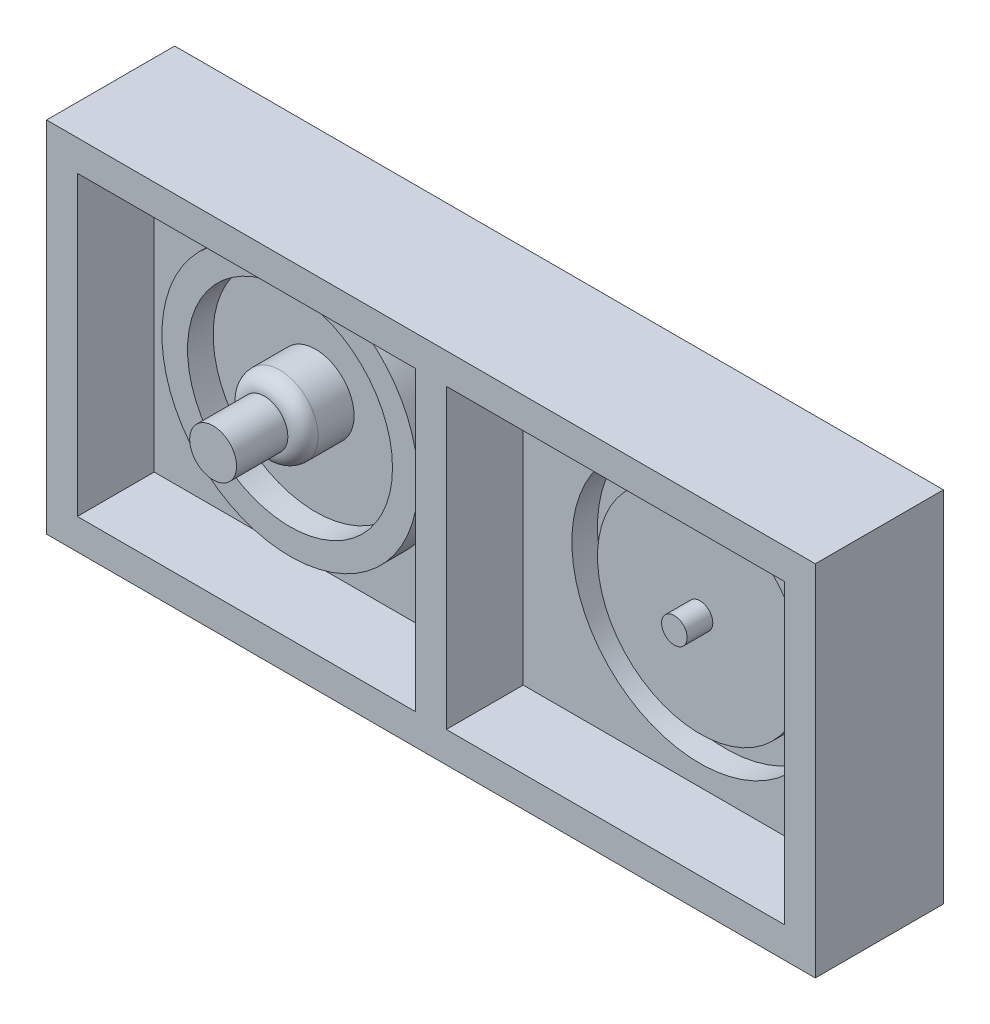
from build123d import *

# Parameters (mm, degrees)
ESQUISSE1_W             = 150
ESQUISSE1_H             = 70
BOSS_EXTRU_1_DEPTH      = 25
ESQUISSE2_W             = 66
ESQUISSE2_H             = 58
ENL_V_MAT_EXTRU_1_DEPTH = 15
ESQUISSE3_R             = 25
ESQUISSE3_R_2           = 20
BOSS_EXTRU_2_DEPTH      = 5
ESQUISSE4_R             = 25
ESQUISSE4_R_2           = 20
ENL_V_MAT_EXTRU_2_DEPTH = 5
ESQUISSE5_R             = 7.5
BOSS_EXTRU_3_DEPTH      = 10
CONG_2_R                = 3
ESQUISSE6_R             = 2.5
BOSS_EXTRU_4_DEPTH      = 5
ESQUISSE7_R             = 4.575268676
BOSS_EXTRU_5_DEPTH      = 10


with BuildPart() as part:
    # Esquisse1 → Boss.-Extru.1 (new body)
    with BuildSketch(Plane.XY):
        with Locations((75, 35)):
            Rectangle(ESQUISSE1_W, ESQUISSE1_H)
    extrude(amount=BOSS_EXTRU_1_DEPTH)

    # Esquisse2 → Enlèv. mat.-Extru.1 (cut)
    with BuildSketch(Plane.XY.offset(25)):
        with Locations((39, 35)):
            Rectangle(ESQUISSE2_W, ESQUISSE2_H)
        with Locations((111, 35)):
            Rectangle(ESQUISSE2_W, ESQUISSE2_H)
    extrude(amount=-ENL_V_MAT_EXTRU_1_DEPTH, mode=Mode.SUBTRACT)

    # Esquisse3 → Boss.-Extru.2 (add)
    with BuildSketch(Plane.XY.offset(10)):
        with Locations((37.5, 35)):
            Circle(ESQUISSE3_R)
        with Locations((37.5, 35)):
            Circle(ESQUISSE3_R_2, mode=Mode.SUBTRACT)
    extrude(amount=BOSS_EXTRU_2_DEPTH)

    # Esquisse4 → Enlèv. mat.-Extru.2 (cut)
    with BuildSketch(Plane.XY.offset(10)):
        with Locations((112.5, 35)):
            Circle(ESQUISSE4_R)
        with Locations((112.5, 35)):
            Circle(ESQUISSE4_R_2, mode=Mode.SUBTRACT)
    extrude(amount=-ENL_V_MAT_EXTRU_2_DEPTH, mode=Mode.SUBTRACT)

    # Esquisse5 → Boss.-Extru.3 (add)
    with BuildSketch(Plane.XY.offset(10)):
        with Locations((37.5, 35)):
            Circle(ESQUISSE5_R)
    extrude(amount=BOSS_EXTRU_3_DEPTH)

    # Congé2
    cong_2_edges = [part.edges().sort_by_distance(p)[0] for p in [
        (30, 35, 20),
    ]]
    fillet(cong_2_edges, radius=CONG_2_R)

    # Esquisse6 → Boss.-Extru.4 (add)
    with BuildSketch(Plane.XY.offset(10)):
        with Locations((112.5, 35)):
            Circle(ESQUISSE6_R)
    extrude(amount=BOSS_EXTRU_4_DEPTH)

    # Esquisse7 → Boss.-Extru.5 (add)
    with BuildSketch(Plane.XY.offset(20)):
        with Locations((37.5, 35)):
            Circle(ESQUISSE7_R)
    extrude(amount=BOSS_EXTRU_5_DEPTH)


solid = part.part
